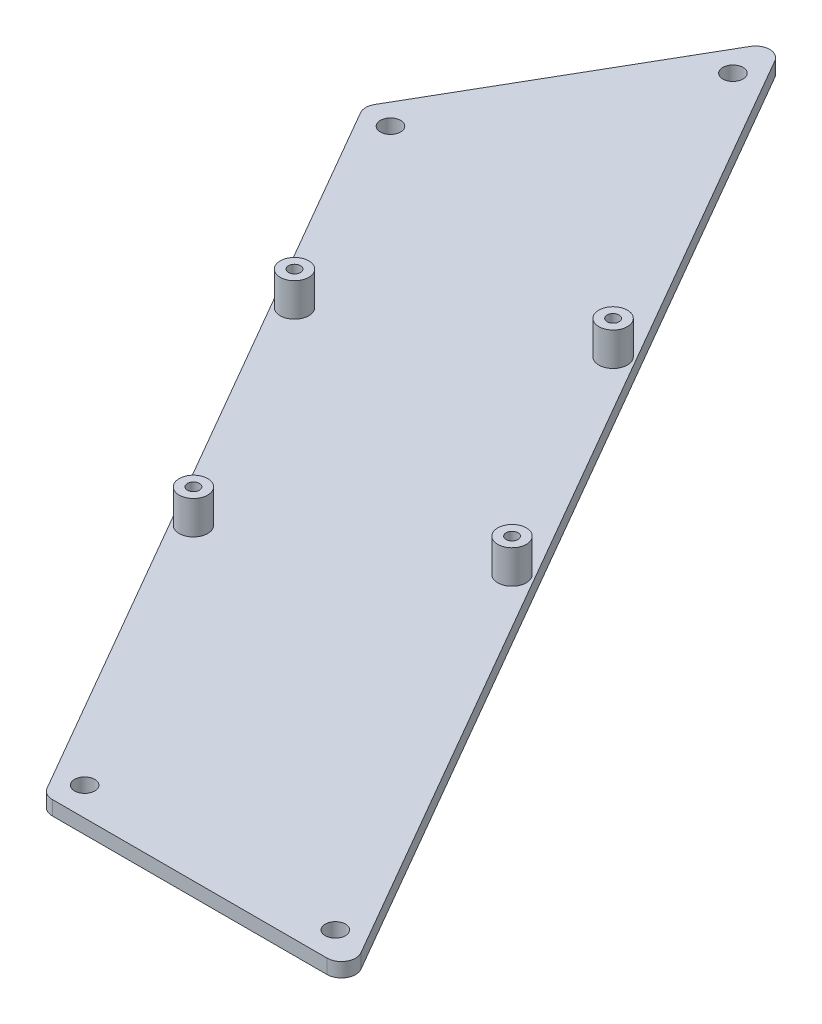
from build123d import *

# Parameters (mm, degrees)
BOSS_EXTRUDE1_DEPTH = 3
FILLET1_R           = 3
SKETCH2_R           = 3
BOSS_EXTRUDE2_DEPTH = 7
SKETCH3_R           = 1.25
CUT_EXTRUDE1_DEPTH  = 11
SKETCH4_R           = 2.125
CUT_EXTRUDE2_DEPTH  = 4


with BuildPart() as part:
    # Sketch1 → Boss-Extrude1 (new body)
    with BuildSketch(Plane(origin=(0, 0, 0), x_dir=(1, 0, 0), z_dir=(0, 1, 0))):
        Polygon((81.303847577, 152.822394855), (113.635462652, 208.822394855), (237.663230149, -6), (173, -6), align=None)
    extrude(amount=BOSS_EXTRUDE1_DEPTH)

    # Fillet1
    fillet1_edges = [part.edges().sort_by_distance(p)[0] for p in [
        (173, 1.5, 6),
        (81.303847577, 1.5, -152.822394855),
        (113.635462652, 1.5, -208.822394855),
        (237.663230149, 1.5, 6),
    ]]
    fillet(fillet1_edges, radius=FILLET1_R)

    # Sketch2 → Boss-Extrude2 (add)
    with BuildSketch(Plane(origin=(0, 3, 0), x_dir=(1, 0, 0), z_dir=(0, 1, 0))):
        with Locations((110.683012702, 108.936188175)):
            Circle(SKETCH2_R)
        with Locations((153.118257487, 133.436188175)):
            Circle(SKETCH2_R)
        with Locations((182.118257487, 83.206714755)):
            Circle(SKETCH2_R)
        with Locations((139.683012702, 58.706714755)):
            Circle(SKETCH2_R)
    extrude(amount=BOSS_EXTRUDE2_DEPTH)

    # Sketch3 → Cut-Extrude1 (cut, through all)
    with BuildSketch(Plane(origin=(0, 10, 0), x_dir=(1, 0, 0), z_dir=(0, 1, 0))):
        with Locations((110.683012702, 108.936188175)):
            Circle(SKETCH3_R)
        with Locations((153.118257487, 133.436188175)):
            Circle(SKETCH3_R)
        with Locations((182.118257487, 83.206714755)):
            Circle(SKETCH3_R)
        with Locations((139.683012702, 58.706714755)):
            Circle(SKETCH3_R)
    extrude(amount=-CUT_EXTRUDE1_DEPTH, mode=Mode.SUBTRACT)

    # Sketch4 → Cut-Extrude2 (cut, through all)
    with BuildSketch(Plane(origin=(0, 3, 0), x_dir=(1, 0, 0), z_dir=(0, 1, 0))):
        with Locations((87.767949192, 152.018547277)):
            Circle(SKETCH4_R)
        with Locations((114.099564267, 197.626242432)):
            Circle(SKETCH4_R)
        with Locations((175.535898385, 0)):
            Circle(SKETCH4_R)
        with Locations((228.199128534, 0)):
            Circle(SKETCH4_R)
    extrude(amount=-CUT_EXTRUDE2_DEPTH, mode=Mode.SUBTRACT)


solid = part.part
